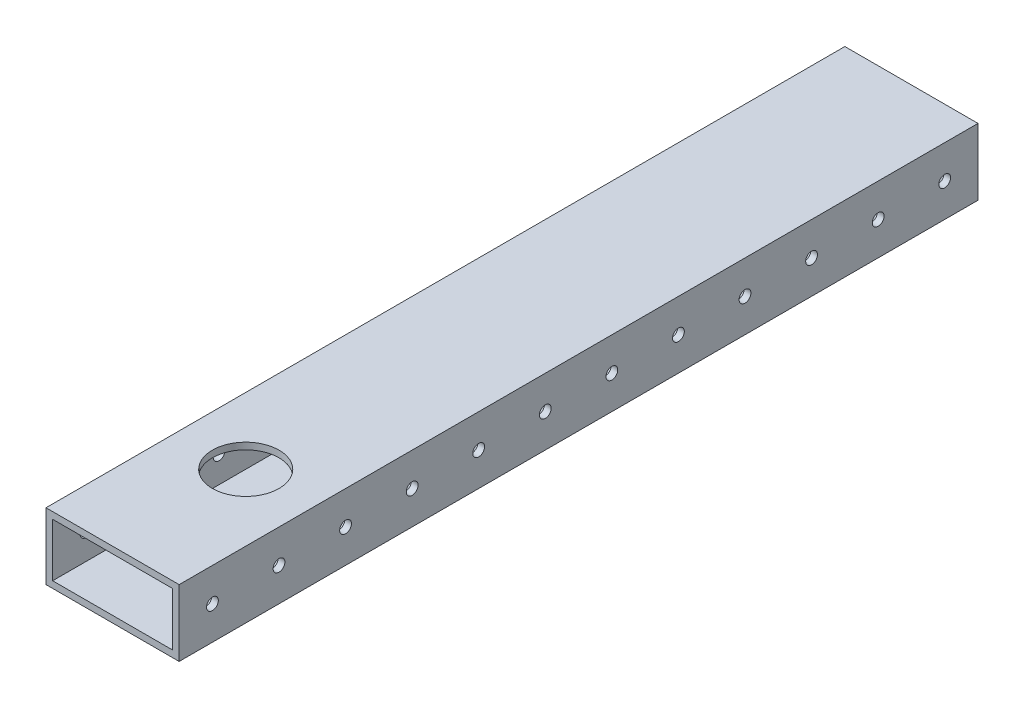
from build123d import *

# Parameters (mm, degrees)
SKETCH1_W               = 50.8
SKETCH1_H               = 25.4
SKETCH1_W_2             = 45.72
SKETCH1_H_2             = 20.32
BOSS_EXTRUDE1_DEPTH     = 355.6
F_8_CLEARANCE_HOLE1_D   = 4.4958
F_1_1_DIAMETER_HOLE1_D  = 25.4
SKETCH8_W               = 50.8
SKETCH8_H               = 50.8
CUT_EXTRUDE1_DEPTH      = 421.64
CUT_EXTRUDE1_DEPTH_BACK = 71.882


with BuildPart() as part:
    # Sketch1 → Boss-Extrude1 (new body)
    with BuildSketch(Plane.XY):
        Rectangle(SKETCH1_W, SKETCH1_H)
        Rectangle(SKETCH1_W_2, SKETCH1_H_2, mode=Mode.SUBTRACT)
    extrude(amount=-BOSS_EXTRUDE1_DEPTH)

    # #8 Clearance Hole1 (through all)
    with Locations(Plane(origin=(25.4, 0, 0), x_dir=(0, 0, -1), z_dir=(1, 0, 0))):
        with Locations((12.7, 0), (38.1, 0), (63.5, 0), (88.9, 0), (114.3, 0), (139.7, 0), (165.1, 0), (190.5, 0), (215.9, 0), (241.3, 0), (266.7, 0), (292.1, 0), (317.5, 0), (342.9, 0)):
            Hole(F_8_CLEARANCE_HOLE1_D / 2)

    # 1 (1) Diameter Hole1 (through all)
    with Locations(Plane(origin=(0, 12.7, 0), x_dir=(1, 0, 0), z_dir=(0, 1, 0))):
        with Locations((0, 101.6)):
            Hole(F_1_1_DIAMETER_HOLE1_D / 2)

    # Sketch8 → Cut-Extrude1 (cut, two sides)
    with BuildSketch(Plane(origin=(0, 12.7, 0), x_dir=(1, 0, 0), z_dir=(0, 1, 0))) as cut_extrude1_sk:
        with Locations((0, 25.4)):
            Rectangle(SKETCH8_W, SKETCH8_H)
    extrude(amount=CUT_EXTRUDE1_DEPTH, mode=Mode.SUBTRACT)
    extrude(cut_extrude1_sk.sketch, amount=-CUT_EXTRUDE1_DEPTH_BACK, mode=Mode.SUBTRACT)


solid = part.part
